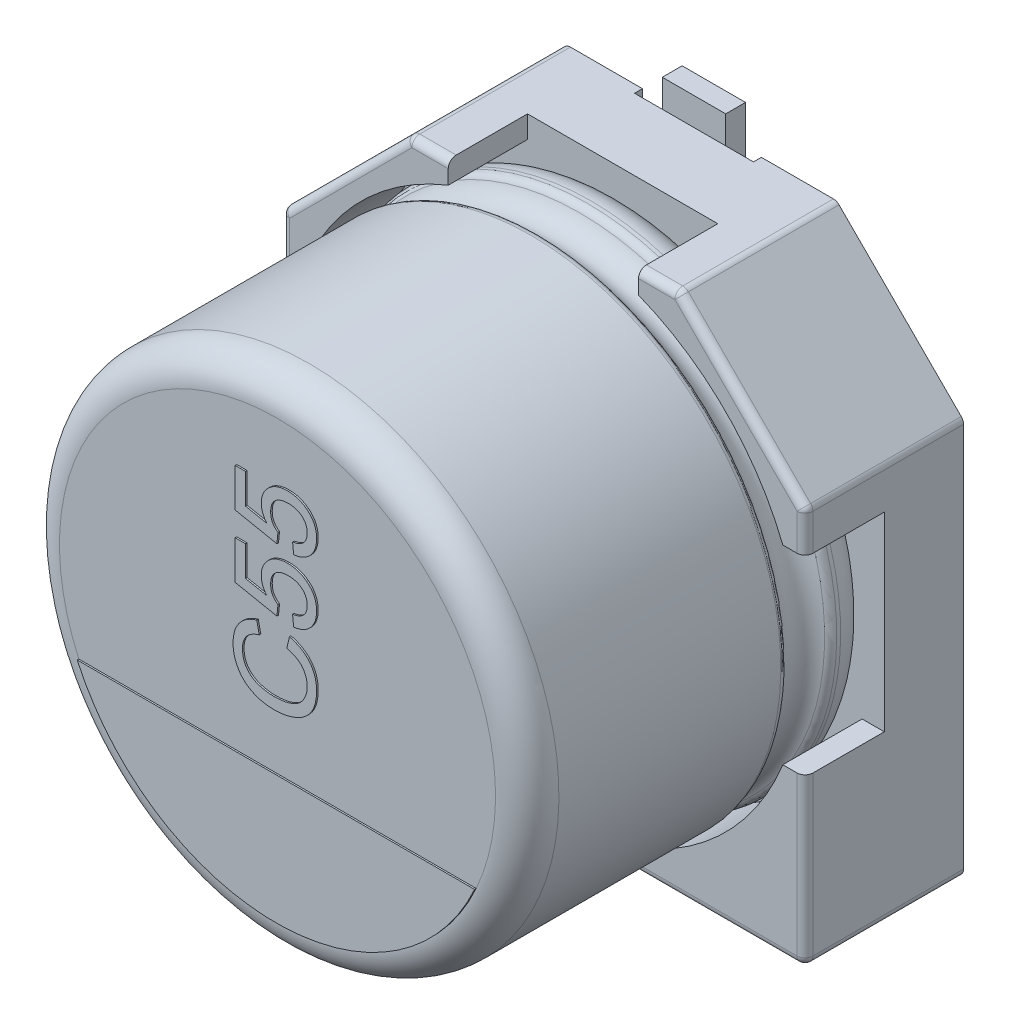
from build123d import *

# Parameters (mm, degrees)
BOSS_EXTRUDE1_DEPTH = 1
BOSS_EXTRUDE2_DEPTH = 1
SKETCH7_R           = 0.35
BOSS_EXTRUDE3_DEPTH = 0.15
SKETCH9_W           = 1.5
SKETCH9_H           = 2.35
CUT_EXTRUDE1_DEPTH  = 0.1
FILLET1_R           = 0.1
FILLET2_R           = 0.1
BOSS_EXTRUDE4_DEPTH = 0.02
TEXT_2_DEPTH        = 0.02
SKETCH19_W          = 0.8
SKETCH19_H          = 2.6
BOSS_EXTRUDE6_DEPTH = 0.25


with BuildPart() as part:
    # Sketch2 → Boss-Extrude1 (new body)
    with BuildSketch(Plane.XY):
        Polygon((-3.3, 1.7), (-1.7, 3.3), (1.7, 3.3), (3.3, 1.7), (3.3, -3.3), (-3.3, -3.3), align=None)
    extrude(amount=BOSS_EXTRUDE1_DEPTH)

    # Sketch4 → Boss-Extrude2 (add)
    with BuildSketch(Plane.XY.offset(1)):
        with BuildLine():
            Line((-3.3, 1.7), (-1.7, 3.3))
            Line((-1.7, 3.3), (-1.2, 3.3))
            Line((-1.2, 3.3), (-1.2, 3.020347662))
            ThreePointArc((-1.2, 3.020347662), (-2.298097039, 2.298097039), (-3.020347662, 1.2))
            Line((-3.020347662, 1.2), (-3.3, 1.2))
            Line((-3.3, 1.2), (-3.3, 1.7))
        make_face()
        with BuildLine():
            Line((1.7, 3.3), (3.3, 1.7))
            Line((3.3, 1.7), (3.3, 1.2))
            Line((3.3, 1.2), (3.020347662, 1.2))
            ThreePointArc((3.020347662, 1.2), (2.298097039, 2.298097039), (1.2, 3.020347662))
            Line((1.2, 3.020347662), (1.2, 3.3))
            Line((1.2, 3.3), (1.7, 3.3))
        make_face()
        with BuildLine():
            Line((3.3, -1.2), (3.3, -3.3))
            Line((3.3, -3.3), (1.2, -3.3))
            Line((1.2, -3.3), (1.2, -3.020347662))
            ThreePointArc((1.2, -3.020347662), (2.298097039, -2.298097039), (3.020347662, -1.2))
            Line((3.020347662, -1.2), (3.3, -1.2))
        make_face()
        with BuildLine():
            Line((-3.3, -1.2), (-3.3, -3.3))
            Line((-3.3, -3.3), (-1.2, -3.3))
            Line((-1.2, -3.3), (-1.2, -3.020347662))
            ThreePointArc((-1.2, -3.020347662), (-2.298097039, -2.298097039), (-3.020347662, -1.2))
            Line((-3.020347662, -1.2), (-3.3, -1.2))
        make_face()
    extrude(amount=BOSS_EXTRUDE2_DEPTH)

    # Sketch7 → Boss-Extrude3 (add)
    with BuildSketch(Plane(origin=(0, 0, 0), x_dir=(1, 0, 0), z_dir=(0, 0, -1))):
        with Locations((-2.232271432, 1.911844843)):
            Circle(SKETCH7_R)
        with Locations((2.232271432, 1.911844843)):
            Circle(SKETCH7_R)
        with Locations((-2.232271432, -1.911844843)):
            Circle(SKETCH7_R)
        with Locations((2.232271432, -1.911844843)):
            Circle(SKETCH7_R)
    extrude(amount=BOSS_EXTRUDE3_DEPTH)

    # Sketch9 → Cut-Extrude1 (cut)
    with BuildSketch(Plane(origin=(0, 0, 0), x_dir=(1, 0, 0), z_dir=(0, 0, -1))):
        with Locations((0, 2.125)):
            Rectangle(SKETCH9_W, SKETCH9_H)
        with Locations((0, -2.125)):
            Rectangle(SKETCH9_W, SKETCH9_H)
    extrude(amount=-CUT_EXTRUDE1_DEPTH, mode=Mode.SUBTRACT)

    # Fillet1
    fillet1_edges = [part.edges().sort_by_distance(p)[0] for p in [
        (3.3, -3.3, 1),
        (-3.3, -3.3, 1),
        (-3.3, 1.7, 1),
        (-1.7, 3.3, 1),
        (1.7, 3.3, 1),
        (3.3, 1.7, 1),
    ]]
    fillet(fillet1_edges, radius=FILLET1_R)

    # Sketch10 → Revolve1 (revolve)
    with BuildSketch(Plane(origin=(0, 0, 0), x_dir=(0, 0, -1), z_dir=(1, 0, 0))):
        with BuildLine():
            Line((-5.353626625, 0), (-1, 0))
            Line((-1, 0), (-1, 2.75))
            ThreePointArc((-1, 2.75), (-1.117157288, 3.032842712), (-1.4, 3.15))
            Line((-1.4, 3.15), (-1.449422929, 3.15))
            ThreePointArc((-1.449422929, 3.15), (-1.504479696, 3.133479053), (-1.541344666, 3.089375046))
            ThreePointArc((-1.541344666, 3.089375046), (-1.801990181, 2.917472047), (-2.062635697, 3.089375046))
            ThreePointArc((-2.062635697, 3.089375046), (-2.099500666, 3.133479053), (-2.154557434, 3.15))
            Line((-2.154557434, 3.15), (-4.953626625, 3.15))
            ThreePointArc((-4.953626625, 3.15), (-5.236469337, 3.032842712), (-5.353626625, 2.75))
            Line((-5.353626625, 2.75), (-5.353626625, 0))
        make_face()
    revolve(axis=Axis((0, 0, -18.9630778), (0, 0, 1)))

    # Fillet2
    fillet2_edges = [part.edges().sort_by_distance(p)[0] for p in [
        (2.2, -3.3, 2),
        (3.270710678, -3.270710678, 2),
        (3.3, 1.429289322, 2),
        (3.292387953, 1.696846987, 2),
        (1.429289322, 3.3, 2),
        (1.696846987, 3.292387953, 2),
        (-1.429289322, 3.3, 2),
        (-1.696846987, 3.292387953, 2),
        (-2.5, 2.5, 2),
        (-3.292387953, 1.696846987, 2),
        (-3.3, -2.2, 2),
        (-3.270710678, -3.270710678, 2),
        (3.3, -2.2, 2),
        (2.5, 2.5, 2),
        (-3.3, 1.429289322, 2),
        (-2.2, -3.3, 2),
    ]]
    fillet(fillet2_edges, radius=FILLET2_R)

    # Sketch13 → Boss-Extrude4 (add)
    with BuildSketch(Plane.XY.offset(5.353626625)):
        with BuildLine():
            Line((-2.506238836, -1.131930607), (2.506238836, -1.131930607))
            ThreePointArc((2.506238836, -1.131930607), (0, -2.75), (-2.506238836, -1.131930607))
        make_face()
    extrude(amount=BOSS_EXTRUDE4_DEPTH)

    # Sketch15 → Text 2 (add)
    with BuildSketch(Plane.XY.offset(5.353626625)):
        with BuildLine():
            Line((0.137389622, 0.316593633), (0.171139963, 0.461473149))
            add(Edge.make_bspline(
                [(0.171139963, 0.461473149), (0.184719205, 0.457843617), (0.211281888, 0.450743802), (0.249294555, 0.436704736), (0.284973396, 0.420954535), (0.318198658, 0.403080099), (0.348825876, 0.383025378), (0.37700883, 0.360877976), (0.402792333, 0.336641169), (0.425858287, 0.31012897), (0.446489175, 0.282031663), (0.464171898, 0.252152583), (0.479591278, 0.221021834), (0.491950748, 0.188130242), (0.501325327, 0.153719305), (0.508136304, 0.117874786), (0.512336792, 0.080509598), (0.512889354, 0.055039538), (0.513170865, 0.042063415)],
                knots=[0, 0, 0, 0, 1.145367768, 2.240481511, 3.299486216, 4.322926322, 5.312543435, 6.280301985, 7.2416403, 8.192823262, 9.141388579, 10.079393599, 11.019812878, 11.970222822, 12.938950422, 13.923894909, 14.942295558, 16, 16, 16, 16], degree=3))
            add(Edge.make_bspline(
                [(0.513170865, 0.042063415), (0.512974968, 0.028750287), (0.512591712, 0.002704216), (0.509548347, -0.035461334), (0.50408886, -0.071710574), (0.497105361, -0.106172698), (0.487517876, -0.138603304), (0.476080502, -0.169237106), (0.462232577, -0.197809744), (0.446522059, -0.224623591), (0.428664346, -0.249552903), (0.409152567, -0.273167676), (0.387446592, -0.294893809), (0.364059715, -0.315274756), (0.338683214, -0.333866555), (0.311661899, -0.351353217), (0.282519639, -0.366881226), (0.251796737, -0.381026037), (0.219790643, -0.393441241), (0.187133568, -0.404424353), (0.153760439, -0.413403647), (0.119952084, -0.421134241), (0.085424029, -0.426750142), (0.050435341, -0.431208994), (0.014771509, -0.433660561), (-0.009201459, -0.433983161), (-0.021278143, -0.434145675)],
                knots=[0, 0, 0, 0, 1.180680974, 2.309907975, 3.39230657, 4.430402719, 5.425739985, 6.38846843, 7.327253855, 8.238163682, 9.141319901, 10.044148192, 10.951882972, 11.861898394, 12.79276478, 13.739539846, 14.714057202, 15.718574761, 16.737652364, 17.7573291, 18.772768038, 19.801551793, 20.831755737, 21.873891013, 22.928945814, 24, 24, 24, 24], degree=3))
            add(Edge.make_bspline(
                [(-0.021278143, -0.434145675), (-0.034315397, -0.4339132), (-0.060073717, -0.433453889), (-0.098081116, -0.430862244), (-0.134761949, -0.426098769), (-0.17014477, -0.419495443), (-0.204305873, -0.411082573), (-0.23725329, -0.400840529), (-0.268852986, -0.388622281), (-0.299113504, -0.374745627), (-0.327665253, -0.358785546), (-0.354762577, -0.3416054), (-0.379878011, -0.322520006), (-0.403474105, -0.302187934), (-0.425149261, -0.280085417), (-0.444954877, -0.256284136), (-0.463070995, -0.230988325), (-0.479329594, -0.204201975), (-0.493595656, -0.176275134), (-0.506302564, -0.147622628), (-0.516717602, -0.118130488), (-0.525377287, -0.088032537), (-0.532271201, -0.057263976), (-0.536881183, -0.025752912), (-0.539885404, 0.006471539), (-0.540292549, 0.02819978), (-0.540498339, 0.039182288)],
                knots=[0, 0, 0, 0, 1.185610122, 2.34246615, 3.46204209, 4.547238403, 5.613845268, 6.659506797, 7.682407252, 8.692734231, 9.683951048, 10.654680354, 11.607833779, 12.549673105, 13.484816388, 14.419272854, 15.362680812, 16.31159957, 17.265732262, 18.21261905, 19.159670199, 20.10733745, 21.059306249, 22.024427552, 23.00144979, 24, 24, 24, 24], degree=3))
            add(Edge.make_bspline(
                [(-0.540498339, 0.039182288), (-0.54027585, 0.051472155), (-0.539838527, 0.075629106), (-0.53596558, 0.111030265), (-0.53016218, 0.145076857), (-0.521400985, 0.17750367), (-0.510653256, 0.208616176), (-0.496791219, 0.237924274), (-0.481084534, 0.266024209), (-0.462639265, 0.292395393), (-0.442059798, 0.317116672), (-0.419396701, 0.339965227), (-0.394799964, 0.360899322), (-0.368077184, 0.379659831), (-0.339408707, 0.396504218), (-0.308850674, 0.411613497), (-0.276208278, 0.424627676), (-0.253468798, 0.431587541), (-0.241890133, 0.435131419)],
                knots=[0, 0, 0, 0, 1.098215313, 2.158650937, 3.179873416, 4.182349117, 5.157851008, 6.118027029, 7.076341197, 8.032298369, 8.990121974, 9.948357669, 10.905435138, 11.873450097, 12.863034414, 13.874936208, 14.917943528, 16, 16, 16, 16], degree=3))
            Line((-0.241890133, 0.435131419), (-0.210815123, 0.290251903))
            add(Edge.make_bspline(
                [(-0.210815123, 0.290251903), (-0.21970095, 0.287406696), (-0.237093262, 0.281837744), (-0.261880399, 0.271949526), (-0.284890959, 0.26127058), (-0.305968529, 0.249546525), (-0.325118157, 0.236751953), (-0.342572578, 0.223181488), (-0.358006003, 0.208509995), (-0.371774287, 0.193035906), (-0.383503548, 0.176359634), (-0.393897604, 0.158872143), (-0.402497099, 0.140204709), (-0.409770496, 0.120625878), (-0.415306335, 0.099952647), (-0.419201016, 0.078269202), (-0.421455067, 0.05555649), (-0.421789822, 0.040079052), (-0.421960554, 0.032185266)],
                knots=[0, 0, 0, 0, 1.235697765, 2.418642872, 3.532555292, 4.594392283, 5.610119701, 6.580908344, 7.519430642, 8.427315627, 9.319973334, 10.216139639, 11.118687699, 12.038725643, 12.980015607, 13.949697744, 14.954307006, 16, 16, 16, 16], degree=3))
            add(Edge.make_bspline(
                [(-0.421960554, 0.032185266), (-0.42182894, 0.023122531), (-0.421570094, 0.005298806), (-0.418741414, -0.020887312), (-0.414566199, -0.046031584), (-0.408336958, -0.06996279), (-0.400471327, -0.092727501), (-0.391074044, -0.1144289), (-0.379637086, -0.134923416), (-0.366527285, -0.154190234), (-0.351810113, -0.172119905), (-0.335998775, -0.188775555), (-0.319056253, -0.204115277), (-0.300881808, -0.217955028), (-0.281409051, -0.230297385), (-0.260823414, -0.241466755), (-0.238987177, -0.251110914), (-0.208358467, -0.262011565), (-0.168833348, -0.2727293), (-0.120495718, -0.282252213), (-0.071437696, -0.288256875), (-0.038444502, -0.28892902), (-0.021895528, -0.289266159)],
                knots=[0, 0, 0, 0, 0.935100075, 1.839065892, 2.715632844, 3.564034634, 4.388093667, 5.199800233, 6.00171917, 6.806945003, 7.602082793, 8.393428172, 9.17553264, 9.958694158, 10.748327009, 11.553054559, 12.374096334, 13.209545573, 14.906836637, 16.595465087, 18.292327764, 20, 20, 20, 20], degree=3))
            add(Edge.make_bspline(
                [(-0.021895528, -0.289266159), (-0.001088295, -0.28888169), (0.039347759, -0.288134525), (0.097860474, -0.280941105), (0.152411861, -0.269796756), (0.194923463, -0.256480088), (0.226325575, -0.243084208), (0.248317261, -0.232252213), (0.268667217, -0.219887416), (0.287491124, -0.206297945), (0.304734045, -0.191308606), (0.320487583, -0.175128268), (0.334903322, -0.157753307), (0.347306436, -0.138977849), (0.35831932, -0.119524584), (0.368112186, -0.099638997), (0.376394559, -0.079308568), (0.382828475, -0.058451271), (0.388388272, -0.03736), (0.392020193, -0.015802455), (0.394069935, 0.006215216), (0.39444386, 0.020999538), (0.39463308, 0.02848096)],
                knots=[0, 0, 0, 0, 2.106854985, 4.094388766, 5.961441423, 7.741458329, 8.594569961, 9.418076185, 10.222480919, 11.003619353, 11.767127393, 12.533696482, 13.289066307, 14.050325982, 14.809648647, 15.552384038, 16.294338903, 17.030544626, 17.761979889, 18.502240791, 19.242077596, 20, 20, 20, 20], degree=3))
            add(Edge.make_bspline(
                [(0.39463308, 0.02848096), (0.39444584, 0.037409013), (0.394075974, 0.055045074), (0.390838523, 0.080901779), (0.386067714, 0.105827286), (0.378705874, 0.129519626), (0.369692165, 0.152297488), (0.358576684, 0.173974247), (0.345208005, 0.194481731), (0.330029126, 0.214061155), (0.312758155, 0.232351457), (0.293534236, 0.249113535), (0.27226973, 0.264151013), (0.249305901, 0.278094539), (0.223956735, 0.289809664), (0.196977778, 0.300660635), (0.167925608, 0.309702449), (0.147714502, 0.314263574), (0.137389622, 0.316593633)],
                knots=[0, 0, 0, 0, 1.013374089, 2.001772144, 2.95501459, 3.891367103, 4.814208647, 5.733921849, 6.652182523, 7.590185968, 8.54346024, 9.504121027, 10.481158517, 11.497760682, 12.549996529, 13.647863555, 14.798406869, 16, 16, 16, 16], degree=3))
        make_face()
        with BuildLine():
            Line((0.223411834, 0.593181799), (0.210240969, 0.72489045))
            add(Edge.make_bspline(
                [(0.210240969, 0.72489045), (0.217662028, 0.726194572), (0.232097144, 0.728731293), (0.252992401, 0.733565295), (0.272404679, 0.739843288), (0.290502099, 0.746897304), (0.307093304, 0.755282192), (0.32244026, 0.764367287), (0.335998198, 0.775081301), (0.348476211, 0.786345647), (0.359471547, 0.798709129), (0.368740995, 0.812291043), (0.376828026, 0.826712445), (0.383449329, 0.842148984), (0.388295773, 0.858624316), (0.392128479, 0.875928756), (0.394059761, 0.894285128), (0.39443953, 0.906809556), (0.39463308, 0.913192661)],
                knots=[0, 0, 0, 0, 1.237781394, 2.407677316, 3.51963579, 4.58689595, 5.594855907, 6.570874, 7.510833816, 8.428091223, 9.330271693, 10.221190844, 11.124215526, 12.043132878, 12.973586933, 13.941700858, 14.950982896, 16, 16, 16, 16], degree=3))
            add(Edge.make_bspline(
                [(0.39463308, 0.913192661), (0.3944417, 0.92102246), (0.39406745, 0.936333972), (0.390968307, 0.958623449), (0.385705739, 0.979602085), (0.378874887, 0.999469002), (0.369522636, 1.017906785), (0.357976474, 1.0348608), (0.344878756, 1.050929366), (0.329303341, 1.065178349), (0.312336747, 1.07814478), (0.293819768, 1.089336872), (0.274009016, 1.098758743), (0.252909186, 1.106691008), (0.230399493, 1.112548387), (0.206599755, 1.116856967), (0.181494791, 1.119622903), (0.164287513, 1.119883375), (0.155499561, 1.120016401)],
                knots=[0, 0, 0, 0, 1.052750423, 2.05869932, 3.018624241, 3.958205853, 4.878289862, 5.789216265, 6.712947111, 7.659433357, 8.620775926, 9.5811884, 10.56329027, 11.567503128, 12.60809625, 13.686605721, 14.818523251, 16, 16, 16, 16], degree=3))
            add(Edge.make_bspline(
                [(0.155499561, 1.120016401), (0.147124757, 1.119865206), (0.130817071, 1.119570794), (0.107070368, 1.117091362), (0.084741282, 1.112908268), (0.063583705, 1.107495737), (0.043928252, 1.100035245), (0.025489938, 1.091186681), (0.008660077, 1.080346819), (-0.00708535, 1.068286757), (-0.021200492, 1.054512644), (-0.033118941, 1.038838393), (-0.043549991, 1.021878897), (-0.052008922, 1.003292573), (-0.058293589, 0.983068478), (-0.063129076, 0.961407582), (-0.065672343, 0.938085123), (-0.066118205, 0.922047105), (-0.066347197, 0.913810045)],
                knots=[0, 0, 0, 0, 1.165854935, 2.270189951, 3.319242023, 4.32700288, 5.306253956, 6.24172124, 7.169108591, 8.088047231, 8.999810445, 9.905349262, 10.822648491, 11.767237767, 12.739852311, 13.766490849, 14.852878837, 16, 16, 16, 16], degree=3))
            add(Edge.make_bspline(
                [(-0.066347197, 0.913810045), (-0.066045926, 0.903568451), (-0.065468157, 0.883927392), (-0.06065641, 0.855692551), (-0.052780332, 0.83006462), (-0.041429729, 0.807090493), (-0.027498802, 0.786633643), (-0.011552276, 0.768343678), (0.005980659, 0.751706448), (0.019200253, 0.742627461), (0.025848858, 0.738061315)],
                knots=[0, 0, 0, 0, 1.182633468, 2.268023356, 3.298275715, 4.269491976, 5.216938987, 6.149685646, 7.069410919, 8, 8, 8, 8], degree=3))
            Line((0.025848858, 0.738061315), (0.012677993, 0.606352664))
            Line((0.012677993, 0.606352664), (-0.514156609, 0.711719585))
            Line((-0.514156609, 0.711719585), (-0.514156609, 1.199041592))
            Line((-0.514156609, 1.199041592), (-0.382447958, 1.199041592))
            Line((-0.382447958, 1.199041592), (-0.382447958, 0.819350248))
            Line((-0.382447958, 0.819350248), (-0.116355325, 0.767078377))
            add(Edge.make_bspline(
                [(-0.116355325, 0.767078377), (-0.121808832, 0.774345707), (-0.132518657, 0.788617595), (-0.14654176, 0.810879182), (-0.158362302, 0.833459086), (-0.168042331, 0.856225864), (-0.175583057, 0.879360362), (-0.180822005, 0.902722977), (-0.184362794, 0.926393253), (-0.184710424, 0.942265569), (-0.184884983, 0.950235719)],
                knots=[0, 0, 0, 0, 1.093835215, 2.148119334, 3.164235237, 4.159999629, 5.123971815, 6.089888814, 7.040853737, 8, 8, 8, 8], degree=3))
            add(Edge.make_bspline(
                [(-0.184884983, 0.950235719), (-0.184613122, 0.960608272), (-0.184077764, 0.981034344), (-0.179681854, 1.011133856), (-0.172212562, 1.039910224), (-0.162176354, 1.067607243), (-0.148800156, 1.093759776), (-0.132935744, 1.118924209), (-0.113809934, 1.142592678), (-0.092160153, 1.164906161), (-0.068094439, 1.185220151), (-0.042286485, 1.203201065), (-0.014506429, 1.218068182), (0.014653573, 1.230498514), (0.04567042, 1.239886722), (0.078117966, 1.247009099), (0.112397978, 1.250817984), (0.135734837, 1.251417964), (0.14767936, 1.251725052)],
                knots=[0, 0, 0, 0, 0.99184379, 1.95318097, 2.901668786, 3.831684196, 4.764819115, 5.705879134, 6.672196848, 7.669818607, 8.675456628, 9.680130933, 10.672473775, 11.683959944, 12.707147321, 13.767588937, 14.857383263, 16, 16, 16, 16], degree=3))
            add(Edge.make_bspline(
                [(0.14767936, 1.251725052), (0.159076386, 1.251491849), (0.181588765, 1.251031207), (0.214764917, 1.247256149), (0.246732751, 1.241037639), (0.277586934, 1.23271277), (0.307152236, 1.221464755), (0.335524158, 1.207821965), (0.36299875, 1.192084241), (0.37993525, 1.179463404), (0.388459237, 1.173111451)],
                knots=[0, 0, 0, 0, 1.059692978, 2.093196008, 3.100373587, 4.086253034, 5.061402885, 6.037282833, 7.012182238, 8, 8, 8, 8], degree=3))
            add(Edge.make_bspline(
                [(0.388459237, 1.173111451), (0.398407566, 1.165040503), (0.417976997, 1.149164082), (0.44340804, 1.121691386), (0.464920924, 1.092064746), (0.482819959, 1.060457617), (0.49653916, 1.026474701), (0.506016391, 0.990295087), (0.512286706, 0.952030668), (0.51287209, 0.925771781), (0.513170865, 0.912369482)],
                knots=[0, 0, 0, 0, 1.023063757, 2.01247625, 2.982117532, 3.944599247, 4.908953799, 5.902627458, 6.929519989, 8, 8, 8, 8], degree=3))
            add(Edge.make_bspline(
                [(0.513170865, 0.912369482), (0.512946009, 0.901314245), (0.512506147, 0.879687983), (0.5087007, 0.848018732), (0.502588826, 0.817914774), (0.493966122, 0.789261523), (0.482550414, 0.762319055), (0.468955441, 0.736703938), (0.452590601, 0.712885762), (0.434142295, 0.690609729), (0.413454647, 0.670503344), (0.391279735, 0.652255189), (0.367205206, 0.636575627), (0.341567374, 0.623157793), (0.31436974, 0.611989422), (0.285444606, 0.603441364), (0.255070847, 0.596671673), (0.234075489, 0.594357288), (0.223411834, 0.593181799)],
                knots=[0, 0, 0, 0, 1.108915132, 2.169260591, 3.195158146, 4.188014069, 5.165918008, 6.126692062, 7.092678666, 8.060306793, 9.02401023, 9.982884032, 10.937400194, 11.901029891, 12.882656982, 13.882099599, 14.924306988, 16, 16, 16, 16], degree=3))
        make_face()
        with BuildLine():
            Line((0.223411834, 1.383433702), (0.210240969, 1.515142353))
            add(Edge.make_bspline(
                [(0.210240969, 1.515142353), (0.217662028, 1.516446475), (0.232097144, 1.518983196), (0.252992401, 1.523817198), (0.272404679, 1.530095191), (0.290502099, 1.537149207), (0.307093304, 1.545534095), (0.32244026, 1.55461919), (0.335998198, 1.565333204), (0.348476211, 1.576597551), (0.359471547, 1.588961032), (0.368740995, 1.602542946), (0.376828026, 1.616964348), (0.383449329, 1.632400887), (0.388295773, 1.648876219), (0.392128479, 1.666180659), (0.394059761, 1.684537031), (0.39443953, 1.697061459), (0.39463308, 1.703444564)],
                knots=[0, 0, 0, 0, 1.237781394, 2.407677316, 3.51963579, 4.58689595, 5.594855907, 6.570874, 7.510833816, 8.428091223, 9.330271693, 10.221190844, 11.124215526, 12.043132878, 12.973586933, 13.941700858, 14.950982896, 16, 16, 16, 16], degree=3))
            add(Edge.make_bspline(
                [(0.39463308, 1.703444564), (0.3944417, 1.711274363), (0.39406745, 1.726585875), (0.390968307, 1.748875352), (0.385705739, 1.769853988), (0.378874887, 1.789720905), (0.369522636, 1.808158688), (0.357976474, 1.825112703), (0.344878756, 1.841181269), (0.329303341, 1.855430252), (0.312336747, 1.868396683), (0.293819768, 1.879588775), (0.274009016, 1.889010646), (0.252909186, 1.896942911), (0.230399493, 1.90280029), (0.206599755, 1.90710887), (0.181494791, 1.909874806), (0.164287513, 1.910135278), (0.155499561, 1.910268304)],
                knots=[0, 0, 0, 0, 1.052750423, 2.05869932, 3.018624241, 3.958205853, 4.878289862, 5.789216265, 6.712947111, 7.659433357, 8.620775926, 9.5811884, 10.56329027, 11.567503128, 12.60809625, 13.686605721, 14.818523251, 16, 16, 16, 16], degree=3))
            add(Edge.make_bspline(
                [(0.155499561, 1.910268304), (0.147124757, 1.910117109), (0.130817071, 1.909822697), (0.107070368, 1.907343265), (0.084741282, 1.903160171), (0.063583705, 1.89774764), (0.043928252, 1.890287148), (0.025489938, 1.881438584), (0.008660077, 1.870598722), (-0.00708535, 1.85853866), (-0.021200492, 1.844764547), (-0.033118941, 1.829090297), (-0.043549991, 1.8121308), (-0.052008922, 1.793544477), (-0.058293589, 1.773320381), (-0.063129076, 1.751659485), (-0.065672343, 1.728337026), (-0.066118205, 1.712299008), (-0.066347197, 1.704061948)],
                knots=[0, 0, 0, 0, 1.165854935, 2.270189951, 3.319242023, 4.32700288, 5.306253956, 6.24172124, 7.169108591, 8.088047231, 8.999810445, 9.905349262, 10.822648491, 11.767237767, 12.739852311, 13.766490849, 14.852878837, 16, 16, 16, 16], degree=3))
            add(Edge.make_bspline(
                [(-0.066347197, 1.704061948), (-0.066045926, 1.693820354), (-0.065468157, 1.674179295), (-0.06065641, 1.645944454), (-0.052780332, 1.620316523), (-0.041429729, 1.597342396), (-0.027498802, 1.576885546), (-0.011552276, 1.558595582), (0.005980659, 1.541958351), (0.019200253, 1.532879364), (0.025848858, 1.528313218)],
                knots=[0, 0, 0, 0, 1.182633468, 2.268023356, 3.298275715, 4.269491976, 5.216938987, 6.149685646, 7.069410919, 8, 8, 8, 8], degree=3))
            Line((0.025848858, 1.528313218), (0.012677993, 1.396604567))
            Line((0.012677993, 1.396604567), (-0.514156609, 1.501971488))
            Line((-0.514156609, 1.501971488), (-0.514156609, 1.989293495))
            Line((-0.514156609, 1.989293495), (-0.382447958, 1.989293495))
            Line((-0.382447958, 1.989293495), (-0.382447958, 1.609602151))
            Line((-0.382447958, 1.609602151), (-0.116355325, 1.55733028))
            add(Edge.make_bspline(
                [(-0.116355325, 1.55733028), (-0.121808832, 1.56459761), (-0.132518657, 1.578869498), (-0.14654176, 1.601131085), (-0.158362302, 1.623710989), (-0.168042331, 1.646477767), (-0.175583057, 1.669612265), (-0.180822005, 1.69297488), (-0.184362794, 1.716645156), (-0.184710424, 1.732517472), (-0.184884983, 1.740487622)],
                knots=[0, 0, 0, 0, 1.093835215, 2.148119334, 3.164235237, 4.159999629, 5.123971815, 6.089888814, 7.040853737, 8, 8, 8, 8], degree=3))
            add(Edge.make_bspline(
                [(-0.184884983, 1.740487622), (-0.184613122, 1.750860175), (-0.184077764, 1.771286247), (-0.179681854, 1.801385759), (-0.172212562, 1.830162127), (-0.162176354, 1.857859146), (-0.148800156, 1.884011679), (-0.132935744, 1.909176112), (-0.113809934, 1.932844581), (-0.092160153, 1.955158064), (-0.068094439, 1.975472054), (-0.042286485, 1.993452968), (-0.014506429, 2.008320085), (0.014653573, 2.020750417), (0.04567042, 2.030138625), (0.078117966, 2.037261002), (0.112397978, 2.041069887), (0.135734837, 2.041669867), (0.14767936, 2.041976955)],
                knots=[0, 0, 0, 0, 0.99184379, 1.95318097, 2.901668786, 3.831684196, 4.764819115, 5.705879134, 6.672196848, 7.669818607, 8.675456628, 9.680130933, 10.672473775, 11.683959944, 12.707147321, 13.767588937, 14.857383263, 16, 16, 16, 16], degree=3))
            add(Edge.make_bspline(
                [(0.14767936, 2.041976955), (0.159076386, 2.041743752), (0.181588765, 2.04128311), (0.214764917, 2.037508052), (0.246732751, 2.031289542), (0.277586934, 2.022964673), (0.307152236, 2.011716658), (0.335524158, 1.998073868), (0.36299875, 1.982336144), (0.37993525, 1.969715307), (0.388459237, 1.963363354)],
                knots=[0, 0, 0, 0, 1.059692978, 2.093196008, 3.100373587, 4.086253034, 5.061402885, 6.037282833, 7.012182238, 8, 8, 8, 8], degree=3))
            add(Edge.make_bspline(
                [(0.388459237, 1.963363354), (0.398407566, 1.955292406), (0.417976997, 1.939415985), (0.44340804, 1.91194329), (0.464920924, 1.882316649), (0.482819959, 1.85070952), (0.49653916, 1.816726604), (0.506016391, 1.78054699), (0.512286706, 1.742282571), (0.51287209, 1.716023684), (0.513170865, 1.702621385)],
                knots=[0, 0, 0, 0, 1.023063757, 2.01247625, 2.982117532, 3.944599247, 4.908953799, 5.902627458, 6.929519989, 8, 8, 8, 8], degree=3))
            add(Edge.make_bspline(
                [(0.513170865, 1.702621385), (0.512946009, 1.691566148), (0.512506147, 1.669939886), (0.5087007, 1.638270635), (0.502588826, 1.608166677), (0.493966122, 1.579513426), (0.482550414, 1.552570958), (0.468955441, 1.526955841), (0.452590601, 1.503137665), (0.434142295, 1.480861632), (0.413454647, 1.460755247), (0.391279735, 1.442507092), (0.367205206, 1.42682753), (0.341567374, 1.413409697), (0.31436974, 1.402241325), (0.285444606, 1.393693267), (0.255070847, 1.386923576), (0.234075489, 1.384609191), (0.223411834, 1.383433702)],
                knots=[0, 0, 0, 0, 1.108915132, 2.169260591, 3.195158146, 4.188014069, 5.165918008, 6.126692062, 7.092678666, 8.060306793, 9.02401023, 9.982884032, 10.937400194, 11.901029891, 12.882656982, 13.882099599, 14.924306988, 16, 16, 16, 16], degree=3))
        make_face()
    extrude(amount=TEXT_2_DEPTH)

    # Sketch19 → Boss-Extrude6 (add)
    with BuildSketch(Plane(origin=(0, 0, 0.1), x_dir=(1, 0, 0), z_dir=(0, 0, -1))):
        with Locations((0, 2.35)):
            Rectangle(SKETCH19_W, SKETCH19_H)
        with Locations((0, -2.35)):
            Rectangle(SKETCH19_W, SKETCH19_H)
    extrude(amount=BOSS_EXTRUDE6_DEPTH)


solid = part.part
